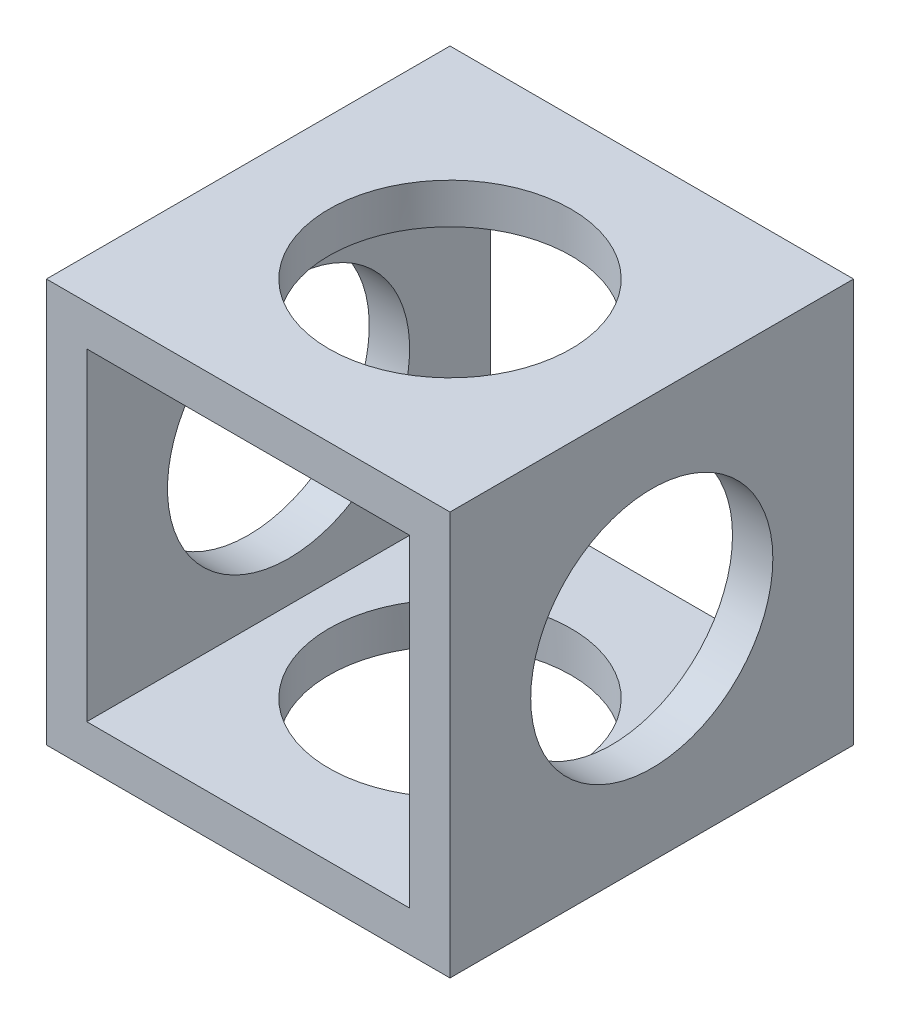
from build123d import *

# Parameters (mm, degrees)
CROQUIS1_W              = 50
CROQUIS1_H              = 50
CROQUIS1_W_2            = 40
CROQUIS1_H_2            = 40
SALIENTE_EXTRUIR1_DEPTH = 50
CROQUIS2_R              = 15
CORTAR_EXTRUIR1_DEPTH   = 50
CROQUIS3_R              = 15
CORTAR_EXTRUIR2_DEPTH   = 50


with BuildPart() as part:
    # Croquis1 → Saliente-Extruir1 (new body)
    with BuildSketch(Plane.XY):
        Rectangle(CROQUIS1_W, CROQUIS1_H)
        Rectangle(CROQUIS1_W_2, CROQUIS1_H_2, mode=Mode.SUBTRACT)
    extrude(amount=-SALIENTE_EXTRUIR1_DEPTH)

    # Croquis2 → Cortar-Extruir1 (cut)
    with BuildSketch(Plane(origin=(0, 25, 0), x_dir=(1, 0, 0), z_dir=(0, 1, 0))):
        with Locations((0, 25)):
            Circle(CROQUIS2_R)
    extrude(amount=-CORTAR_EXTRUIR1_DEPTH, mode=Mode.SUBTRACT)

    # Croquis3 → Cortar-Extruir2 (cut)
    with BuildSketch(Plane(origin=(25, 0, 0), x_dir=(0, 0, -1), z_dir=(1, 0, 0))):
        with Locations((25, 0)):
            Circle(CROQUIS3_R)
    extrude(amount=-CORTAR_EXTRUIR2_DEPTH, mode=Mode.SUBTRACT)


solid = part.part
